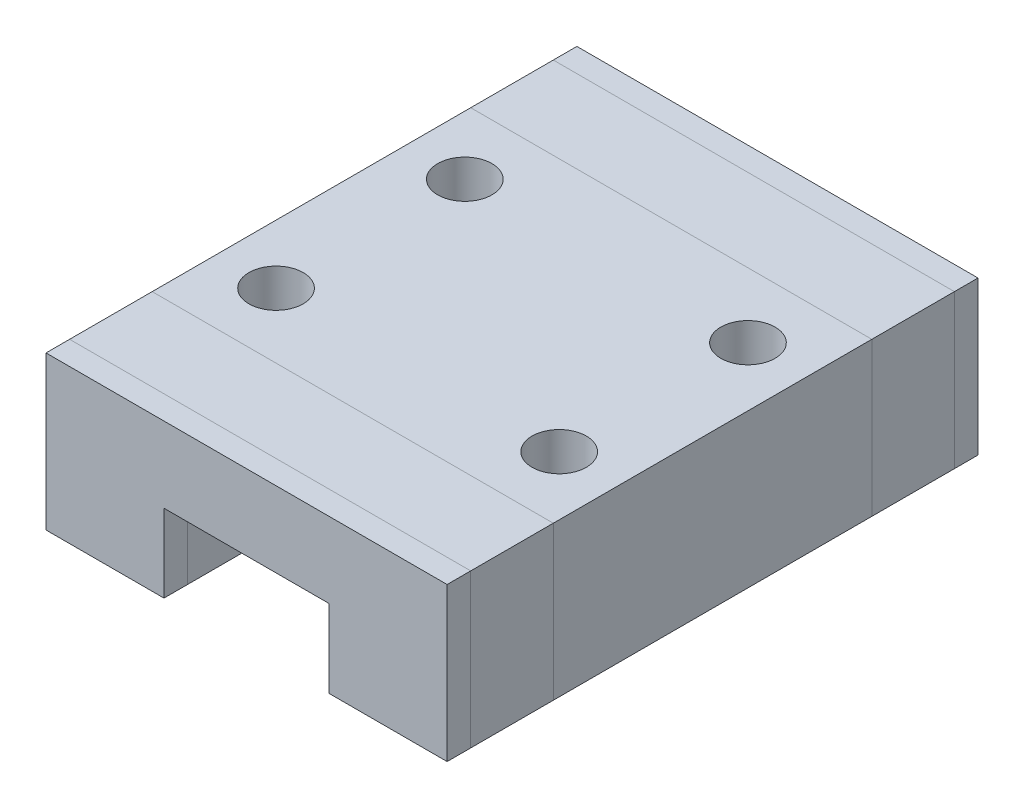
from build123d import *

# Parameters (mm, degrees)
SKETCH_1_W          = 17
SKETCH_1_H          = 6.5
EXTRUDE_1_DEPTH     = 22.5
SKETCH_2_W          = 7
SKETCH_2_H          = 3.3
CUT_EXTRUDE_1_DEPTH = 23.5
SKETCH_3_R          = 1.15
CUT_EXTRUDE_2_DEPTH = 4


with BuildPart() as part:
    # 草图1 → 凸台-拉伸1 (new body)
    with BuildSketch(Plane.XY):
        Rectangle(SKETCH_1_W, SKETCH_1_H)
    extrude(amount=EXTRUDE_1_DEPTH)

    # 草图2 → 切除-拉伸1 (cut, through all)
    with BuildSketch(Plane.XY.offset(22.5)):
        with Locations((0, -1.6)):
            Rectangle(SKETCH_2_W, SKETCH_2_H)
    extrude(amount=-CUT_EXTRUDE_1_DEPTH, mode=Mode.SUBTRACT)

    # 草图3 → 切除-拉伸2 (cut)
    with BuildSketch(Plane(origin=(0, 3.25, 0), x_dir=(1, 0, 0), z_dir=(0, 1, 0))):
        with Locations((-6, -7.25)):
            Circle(SKETCH_3_R)
        with Locations((-6, -15.25)):
            Circle(SKETCH_3_R)
        with Locations((6, -15.25)):
            Circle(SKETCH_3_R)
        with Locations((6, -7.25)):
            Circle(SKETCH_3_R)
    extrude(amount=-CUT_EXTRUDE_2_DEPTH, mode=Mode.SUBTRACT)


solid = part.part
